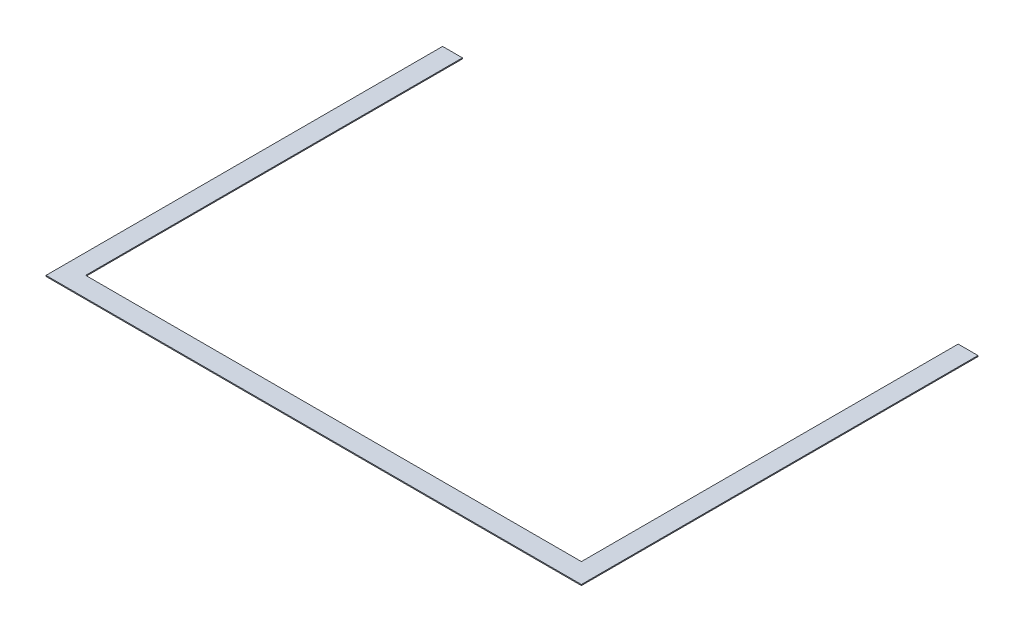
from build123d import *

# Parameters (mm, degrees)
BOSS_EXTRUDE1_DEPTH = 5


with BuildPart() as part:
    # Sketch1 → Boss-Extrude1 (new body)
    with BuildSketch(Plane(origin=(0, 0, 0), x_dir=(1, 0, 0), z_dir=(0, 1, 0))):
        Polygon((-106.62115926, -63.37884074), (2593.37884074, -63.37884074), (2593.37884074, 1936.62115926), (2493.37884074, 1936.62115926), (2493.37884074, 186.62115926), (2493.37884074, 36.62115926), (-6.62115926, 36.62115926), (-6.62115926, 1936.62115926), (-106.62115926, 1936.62115926), align=None)
    extrude(amount=BOSS_EXTRUDE1_DEPTH)


solid = part.part
